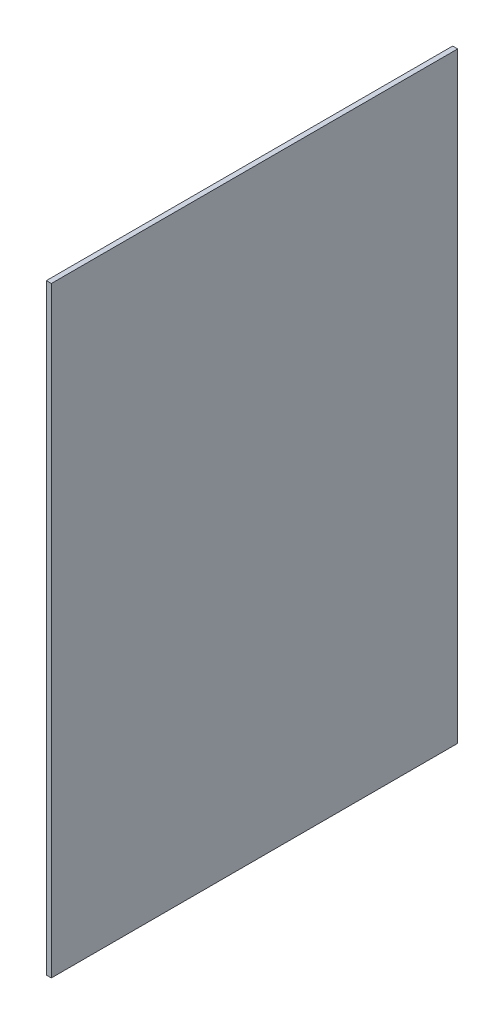
from build123d import *

# Parameters (mm, degrees)
SKETCH2_W           = 317.5
SKETCH2_H           = 469.9
BOSS_EXTRUDE1_DEPTH = 3.9


with BuildPart() as part:
    # Sketch2 → Boss-Extrude1 (new body)
    with BuildSketch(Plane(origin=(0, 0, 0), x_dir=(0, 0, -1), z_dir=(1, 0, 0))):
        with Locations((115.819847027, 212.781150514)):
            Rectangle(SKETCH2_W, SKETCH2_H)
    extrude(amount=BOSS_EXTRUDE1_DEPTH)


solid = part.part
